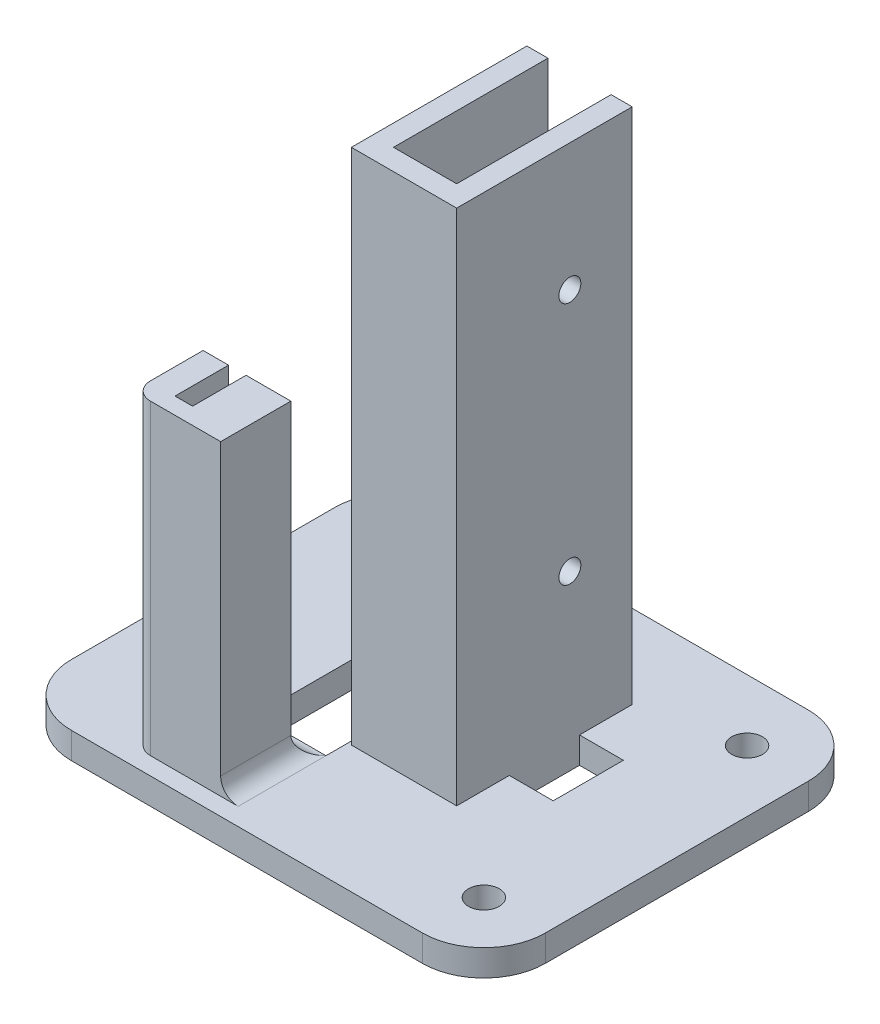
from build123d import *

# Parameters (mm, degrees)
SALIENTE_EXTRUIR1_DEPTH = 3
CORTAR_EXTRUIR1_REACH   = 5
CROQUIS2_W              = 5
CROQUIS2_H              = 8
CROQUIS3_W              = 10
CROQUIS3_H              = 8
SALIENTE_EXTRUIR2_DEPTH = 35
CORTAR_EXTRUIR2_DEPTH   = 12
REDONDEO1_R             = 2
REDONDEO2_R             = 2
SALIENTE_EXTRUIR3_DEPTH = 59
CORTAR_EXTRUIR3_REACH   = 38.4
CROQUIS6_R              = 1.25
CORTAR_EXTRUIR4_REACH   = 5
CROQUIS7_R              = 1.75
CROQUIS7_W              = 8
CROQUIS7_H              = 20


with BuildPart() as part:
    # Croquis1 → Saliente-Extruir1 (new body)
    with BuildSketch(Plane(origin=(0, 0, 0), x_dir=(1, 0, 0), z_dir=(0, 1, 0))):
        with BuildLine():
            Line((7, 0), (47, 0))
            ThreePointArc((47, 0), (51.949747468, 2.050252532), (54, 7))
            Line((54, 7), (54, 37))
            ThreePointArc((54, 37), (51.949747468, 41.949747468), (47, 44))
            Line((47, 44), (7, 44))
            ThreePointArc((7, 44), (2.050252532, 41.949747468), (0, 37))
            Line((0, 37), (0, 7))
            ThreePointArc((0, 7), (2.050252532, 2.050252532), (7, 0))
        make_face()
    extrude(amount=SALIENTE_EXTRUIR1_DEPTH)

    # Croquis2 → Cortar-Extruir1 (cut, up to next)
    with BuildSketch(Plane(origin=(0, 3, 0), x_dir=(1, 0, 0), z_dir=(0, 1, 0)), mode=Mode.PRIVATE) as cortar_extruir1_sk1:
        with Locations((38.9, 24.5)):
            Rectangle(CROQUIS2_W, CROQUIS2_H)
    cortar_extruir1_tool1 = extrude(cortar_extruir1_sk1.sketch, amount=-CORTAR_EXTRUIR1_REACH, mode=Mode.PRIVATE) & part.part
    add(cortar_extruir1_tool1.solids().sort_by_distance((38.9, 3, -24.5))[0], mode=Mode.SUBTRACT)

    # Croquis3 → Saliente-Extruir2 (add)
    with BuildSketch(Plane(origin=(0, 3, 0), x_dir=(1, 0, 0), z_dir=(0, 1, 0))):
        with Locations((17, 38)):
            Rectangle(CROQUIS3_W, CROQUIS3_H)
        with Locations((17, 6)):
            Rectangle(CROQUIS3_W, CROQUIS3_H)
    extrude(amount=SALIENTE_EXTRUIR2_DEPTH)

    # Croquis4 → Cortar-Extruir2 (cut)
    with BuildSketch(Plane(origin=(0, 38, 0), x_dir=(1, 0, 0), z_dir=(0, 1, 0))):
        with BuildLine():
            Line((14.9, 10.594122727), (14.9, 3.9))
            Line((14.9, 3.9), (16.9, 3.9))
            Line((16.9, 3.9), (16.9, 10.101282262))
            ThreePointArc((16.9, 10.101282262), (15.866874644, 10.213276209), (14.9, 10.594122727))
        make_face()
        with BuildLine():
            Line((16.9, 17.898717738), (16.9, 40.1))
            Line((16.9, 40.1), (14.9, 40.1))
            Line((14.9, 40.1), (14.9, 17.405877273))
            ThreePointArc((14.9, 17.405877273), (15.866874644, 17.786723791), (16.9, 17.898717738))
        make_face()
    extrude(amount=-CORTAR_EXTRUIR2_DEPTH, mode=Mode.SUBTRACT)

    # Redondeo1
    redondeo1_edges = [part.edges().sort_by_distance(p)[0] for p in [
        (12, 20.5, -42),
        (12, 20.5, -2),
    ]]
    fillet(redondeo1_edges, radius=REDONDEO1_R)

    # Redondeo2
    redondeo2_edges = [part.edges().sort_by_distance(p)[0] for p in [
        (17, 3, -34),
        (22, 3, -38),
        (22, 3, -6),
        (17, 3, -10),
    ]]
    fillet(redondeo2_edges, radius=REDONDEO2_R)

    # Croquis5 → Saliente-Extruir3 (add)
    with BuildSketch(Plane(origin=(0, 3, 0), x_dir=(1, 0, 0), z_dir=(0, 1, 0))):
        Polygon((36.4, 34.5), (36.4, 14.5), (24.4, 14.5), (24.4, 34.5), (26.8, 34.5), (26.8, 16.9), (34, 16.9), (34, 34.5), align=None)
    extrude(amount=SALIENTE_EXTRUIR3_DEPTH)

    # Croquis6 → Cortar-Extruir3 (cut, up to next)
    with BuildSketch(Plane(origin=(36.4, 0, 0), x_dir=(0, 0, -1), z_dir=(1, 0, 0)), mode=Mode.PRIVATE) as cortar_extruir3_sk1:
        with Locations((27.4, 47.5)):
            Circle(CROQUIS6_R)
    cortar_extruir3_tool1 = extrude(cortar_extruir3_sk1.sketch, amount=-CORTAR_EXTRUIR3_REACH, mode=Mode.PRIVATE) & part.part
    add(cortar_extruir3_tool1.solids().sort_by_distance((36.4, 47.5, -27.4))[0], mode=Mode.SUBTRACT)
    # Croquis6 → Cortar-Extruir3 (cut, up to next)
    with BuildSketch(Plane(origin=(36.4, 0, 0), x_dir=(0, 0, -1), z_dir=(1, 0, 0)), mode=Mode.PRIVATE) as cortar_extruir3_sk2:
        with Locations((27.4, 19.7)):
            Circle(CROQUIS6_R)
    cortar_extruir3_tool2 = extrude(cortar_extruir3_sk2.sketch, amount=-CORTAR_EXTRUIR3_REACH, mode=Mode.PRIVATE) & part.part
    add(cortar_extruir3_tool2.solids().sort_by_distance((36.4, 19.7, -27.4))[0], mode=Mode.SUBTRACT)

    # Croquis7 → Cortar-Extruir4 (cut, up to next)
    with BuildSketch(Plane(origin=(0, 3, 0), x_dir=(1, 0, 0), z_dir=(0, 1, 0)), mode=Mode.PRIVATE) as cortar_extruir4_sk1:
        with Locations((4, 22)):
            Circle(CROQUIS7_R)
    cortar_extruir4_tool1 = extrude(cortar_extruir4_sk1.sketch, amount=-CORTAR_EXTRUIR4_REACH, mode=Mode.PRIVATE) & part.part
    add(cortar_extruir4_tool1.solids().sort_by_distance((4, 3, -22))[0], mode=Mode.SUBTRACT)
    # Croquis7 → Cortar-Extruir4 (cut, up to next)
    with BuildSketch(Plane(origin=(0, 3, 0), x_dir=(1, 0, 0), z_dir=(0, 1, 0)), mode=Mode.PRIVATE) as cortar_extruir4_sk2:
        with Locations((47, 37)):
            Circle(CROQUIS7_R)
    cortar_extruir4_tool2 = extrude(cortar_extruir4_sk2.sketch, amount=-CORTAR_EXTRUIR4_REACH, mode=Mode.PRIVATE) & part.part
    add(cortar_extruir4_tool2.solids().sort_by_distance((47, 3, -37))[0], mode=Mode.SUBTRACT)
    # Croquis7 → Cortar-Extruir4 (cut, up to next)
    with BuildSketch(Plane(origin=(0, 3, 0), x_dir=(1, 0, 0), z_dir=(0, 1, 0)), mode=Mode.PRIVATE) as cortar_extruir4_sk3:
        with Locations((47, 7)):
            Circle(CROQUIS7_R)
    cortar_extruir4_tool3 = extrude(cortar_extruir4_sk3.sketch, amount=-CORTAR_EXTRUIR4_REACH, mode=Mode.PRIVATE) & part.part
    add(cortar_extruir4_tool3.solids().sort_by_distance((47, 3, -7))[0], mode=Mode.SUBTRACT)
    # Croquis7 → Cortar-Extruir4 (cut, up to next)
    with BuildSketch(Plane(origin=(0, 3, 0), x_dir=(1, 0, 0), z_dir=(0, 1, 0)), mode=Mode.PRIVATE) as cortar_extruir4_sk4:
        with Locations((20, 22)):
            Rectangle(CROQUIS7_W, CROQUIS7_H)
    cortar_extruir4_tool4 = extrude(cortar_extruir4_sk4.sketch, amount=-CORTAR_EXTRUIR4_REACH, mode=Mode.PRIVATE) & part.part
    add(cortar_extruir4_tool4.solids().sort_by_distance((20, 3, -22))[0], mode=Mode.SUBTRACT)


solid = part.part
